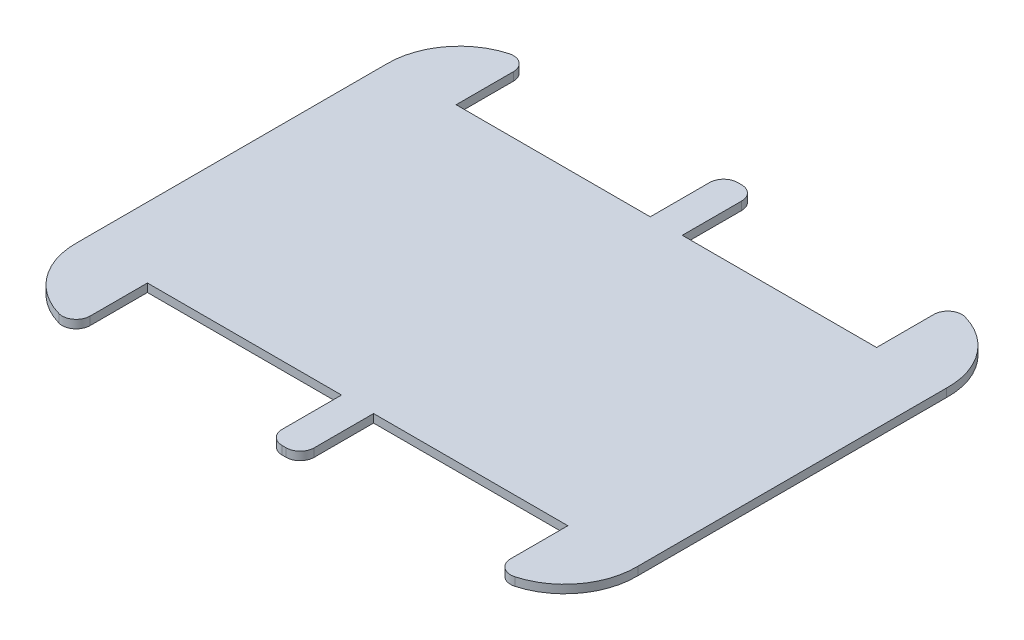
from build123d import *

# Parameters (mm, degrees)
BOSS_EXTRUDE1_DEPTH = 3
FILLET1_R           = 5.08
FILLET2_R           = 5.08
FILLET3_R           = 5.08


with BuildPart() as part:
    # Sketch1 → Boss-Extrude1 (new body)
    with BuildSketch(Plane(origin=(0, 0, 0), x_dir=(1, 0, 0), z_dir=(0, 1, 0))):
        with BuildLine():
            Line((-76.2, 82.55), (-76.2, 55.95))
            Line((-76.2, 55.95), (-5.842, 55.95))
            Line((-5.842, 55.95), (-5.842, 82.55))
            Line((-5.842, 82.55), (5.770221656, 82.55))
            Line((5.770221656, 82.55), (5.770221656, 55.949868395))
            Line((5.770221656, 55.949868395), (76.2, 55.95))
            Line((76.2, 55.95), (76.2, 82.55))
            ThreePointArc((76.2, 82.55), (94.40904038, 74.510512242), (101.6, 55.95))
            Line((101.6, 55.95), (101.6, -55.95))
            ThreePointArc((101.6, -55.95), (94.40904038, -74.510512242), (76.2, -82.55))
            Line((76.2, -82.55), (76.2, -55.95))
            Line((76.2, -55.95), (5.770221656, -55.95))
            Line((5.770221656, -55.95), (5.770221656, -82.55))
            Line((5.770221656, -82.55), (-5.842, -82.55))
            Line((-5.842, -82.55), (-5.842, -55.95))
            Line((-5.842, -55.95), (-76.2, -55.95))
            Line((-76.2, -55.95), (-76.2, -82.55))
            ThreePointArc((-76.2, -82.55), (-94.40904038, -74.510512242), (-101.6, -55.95))
            Line((-101.6, -55.95), (-101.6, 55.95))
            ThreePointArc((-101.6, 55.95), (-94.40904038, 74.510512242), (-76.2, 82.55))
        make_face()
    extrude(amount=BOSS_EXTRUDE1_DEPTH)

    # Fillet1
    fillet1_edges = [part.edges().sort_by_distance(p)[0] for p in [
        (5.770221656, 1.5, 82.55),
        (-5.842, 1.5, 82.55),
    ]]
    fillet(fillet1_edges, radius=FILLET1_R)

    # Fillet2
    fillet2_edges = [part.edges().sort_by_distance(p)[0] for p in [
        (-5.842, 1.5, -82.55),
        (5.770221656, 1.5, -82.55),
    ]]
    fillet(fillet2_edges, radius=FILLET2_R)

    # Fillet3
    fillet3_edges = [part.edges().sort_by_distance(p)[0] for p in [
        (-76.2, 1.5, -82.55),
        (76.2, 1.5, -82.55),
        (76.2, 1.5, 82.55),
        (-76.2, 1.5, 82.55),
    ]]
    fillet(fillet3_edges, radius=FILLET3_R)


solid = part.part
